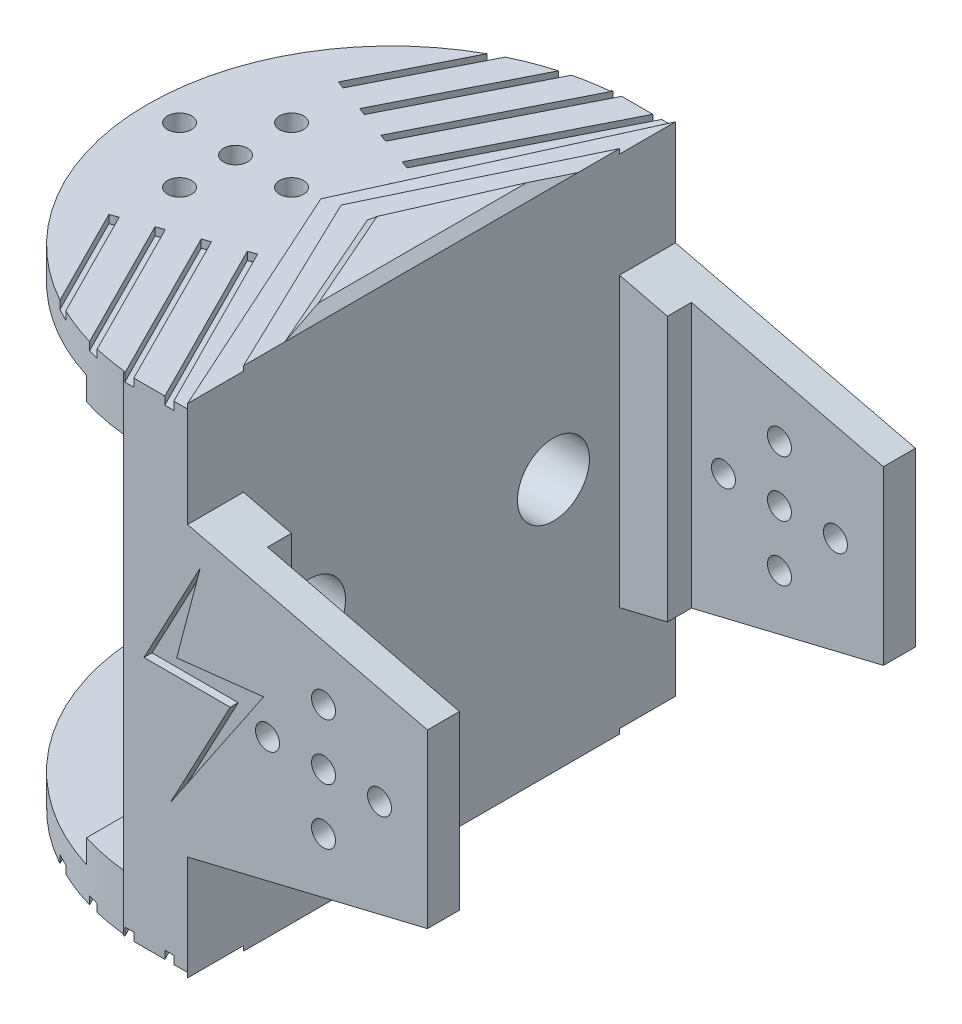
from build123d import *

# Parameters (mm, degrees)
EXTRUDE_1_DEPTH      = 61
SKETCH_2_W           = 40
SKETCH_2_H           = 53
CUT_EXTRUDE_1_DEPTH  = 61
SKETCH_3_R           = 4
CUT_EXTRUDE_2_DEPTH  = 61
SKETCH_6_W           = 61
SKETCH_6_H           = 61
EXTRUDE_3_DEPTH      = 6
EXTRUDE_4_DEPTH      = 6
CUT_EXTRUDE_4_DEPTH  = 6
SKETCH_21_R          = 4
SKETCH_21_R_2        = 1.5
EXTRUDE_10_DEPTH     = 4
SKETCH_22_R          = 1.5
CUT_EXTRUDE_11_DEPTH = 4
SKETCH_23_W          = 61
SKETCH_23_H          = 61
CUT_EXTRUDE_12_DEPTH = 2
CUT_EXTRUDE_START    = -103
SKETCH_24_W          = 18.957699184
SKETCH_24_H          = 3.1
CUT_EXTRUDE_13_DEPTH = 141
SKETCH_25_R          = 4
SKETCH_25_R_2        = 1.5
EXTRUDE_11_DEPTH     = 4
SKETCH_26_R          = 1.5
EXTRUDE_12_DEPTH     = 7
CUT_EXTRUDE_14_DEPTH = 3
SKETCH_30_R          = 4.5
CUT_EXTRUDE_15_DEPTH = 46
EXTRUDE_14_DEPTH     = 0.6
EXTRUDE_15_DEPTH     = 0.6
EXTRUDE_16_DEPTH     = 1
EXTRUDE_16_TAPER     = 48
CUT_EXTRUDE_16_DEPTH = 1
CUT_EXTRUDE_17_DEPTH = 1


with BuildPart() as part:
    # 草图1 → 凸台-拉伸1 (new body)
    with BuildSketch(Plane(origin=(0, 0, 0), x_dir=(1, 0, 0), z_dir=(0, 1, 0))):
        with BuildLine():
            Line((43.616831607, -30.5), (50.616831607, -30.5))
            Line((50.616831607, -30.5), (50.616831607, 30.5))
            Line((50.616831607, 30.5), (43.616831607, 30.5))
            ThreePointArc((43.616831607, 30.5), (13.116831607, 0), (43.616831607, -30.5))
        make_face()
    extrude(amount=EXTRUDE_1_DEPTH)

    # 草图2 → 切除-拉伸1 (cut)
    with BuildSketch(Plane.XY.offset(30.5)):
        with Locations((26.616831607, 30.5)):
            Rectangle(SKETCH_2_W, SKETCH_2_H)
    extrude(amount=-CUT_EXTRUDE_1_DEPTH, mode=Mode.SUBTRACT)

    # 草图3 → 切除-拉伸2 (cut)
    with BuildSketch(Plane(origin=(0, 61, 0), x_dir=(1, 0, 0), z_dir=(0, 1, 0))):
        with Locations((24.116831607, 0)):
            Circle(SKETCH_3_R)
    extrude(amount=-CUT_EXTRUDE_2_DEPTH, mode=Mode.SUBTRACT)

    # 草图6 → 凸台-拉伸3 (add)
    with BuildSketch(Plane.ZY.offset(-46.616831607)):
        with Locations((0, 30.5)):
            Rectangle(SKETCH_6_W, SKETCH_6_H)
    extrude(amount=EXTRUDE_3_DEPTH)

    # 草图7 → 凸台-拉伸4 (add)
    with BuildSketch(Plane.XZ.offset(-57)):
        with BuildLine():
            Line((40.616831607, 30.352100422), (40.616831607, -30.352100422))
            ThreePointArc((40.616831607, -30.352100422), (13.116831607, 0), (40.616831607, 30.352100422))
        make_face()
    extrude_4 = extrude(amount=EXTRUDE_4_DEPTH)

    # 草图8 → 切除-拉伸4 (cut)
    with BuildSketch(Plane.XZ.offset(-51)):
        Polygon((9.690406562, -10), (9.690406562, 10), (24.116831607, 30.269119374), (34.616831607, 33.638775852), (34.616831607, -30.352100422), (24.116831607, -25.227142121), align=None)
    cut_extrude_4 = extrude(amount=-CUT_EXTRUDE_4_DEPTH, mode=Mode.SUBTRACT)

    # 草图21 → 凸台-拉伸10 (add)
    with BuildSketch(Plane(origin=(0, 61, 0), x_dir=(1, 0, 0), z_dir=(0, 1, 0))):
        with Locations((24.116831607, 0)):
            Circle(SKETCH_21_R)
        with Locations((24.116831607, 0)):
            Circle(SKETCH_21_R_2, mode=Mode.SUBTRACT)
    extrude(amount=-EXTRUDE_10_DEPTH)

    # 草图22 → 切除-拉伸11 (cut)
    with BuildSketch(Plane(origin=(0, 61, 0), x_dir=(1, 0, 0), z_dir=(0, 1, 0))):
        with Locations((31.116831607, 0)):
            Circle(SKETCH_22_R)
        with Locations((24.116831607, -7)):
            Circle(SKETCH_22_R)
        with Locations((17.116831607, 0)):
            Circle(SKETCH_22_R)
        with Locations((24.116831607, 7)):
            Circle(SKETCH_22_R)
    cut_extrude_11 = extrude(amount=-CUT_EXTRUDE_11_DEPTH, mode=Mode.SUBTRACT)

    # 草图23 → 切除-拉伸12 (cut)
    with BuildSketch(Plane(origin=(50.616831607, 0, 0), x_dir=(0, 0, -1), z_dir=(1, 0, 0))):
        with Locations((0, 30.5)):
            Rectangle(SKETCH_23_W, SKETCH_23_H)
    extrude(amount=-CUT_EXTRUDE_12_DEPTH, mode=Mode.SUBTRACT)

    # 草图24 → 切除-拉伸13 (cut)
    with BuildSketch(Plane.XY.offset(30.5).offset(CUT_EXTRUDE_START)):
        with Locations((31.137982015, 52.55)):
            Rectangle(SKETCH_24_W, SKETCH_24_H)
    cut_extrude_13 = extrude(amount=CUT_EXTRUDE_13_DEPTH, mode=Mode.SUBTRACT)

    # 镜向1: 凸台-拉伸4, 切除-拉伸4, 切除-拉伸11, 切除-拉伸13 across plane
    add(extrude_4.mirror(Plane(origin=(0, 30.5, 0), x_dir=(0, 0, 1), z_dir=(0, -1, 0))))
    add(cut_extrude_4.mirror(Plane(origin=(0, 30.5, 0), x_dir=(0, 0, 1), z_dir=(0, -1, 0))), mode=Mode.SUBTRACT)
    add(cut_extrude_11.mirror(Plane(origin=(0, 30.5, 0), x_dir=(0, 0, 1), z_dir=(0, -1, 0))), mode=Mode.SUBTRACT)
    add(cut_extrude_13.mirror(Plane(origin=(0, 30.5, 0), x_dir=(0, 0, 1), z_dir=(0, -1, 0))), mode=Mode.SUBTRACT)

    # 草图25 → 凸台-拉伸11 (add)
    with BuildSketch(Plane.XZ):
        with Locations((24.116831607, 0)):
            Circle(SKETCH_25_R)
        with Locations((24.116831607, 0)):
            Circle(SKETCH_25_R_2, mode=Mode.SUBTRACT)
    extrude(amount=-EXTRUDE_11_DEPTH)

    # 草图26 → 凸台-拉伸12 (add)
    with BuildSketch(Plane.XY.offset(30.5)):
        Polygon((48.616831607, 12.5), (48.616831607, 48.5), (78.616831607, 41.256266774), (78.616831607, 19.743733226), align=None)
        with Locations((65.616831607, 30.5)):
            Circle(SKETCH_26_R, mode=Mode.SUBTRACT)
        with Locations((65.616831607, 37.5)):
            Circle(SKETCH_26_R, mode=Mode.SUBTRACT)
        with Locations((72.616831607, 30.5)):
            Circle(SKETCH_26_R, mode=Mode.SUBTRACT)
        with Locations((65.616831607, 23.5)):
            Circle(SKETCH_26_R, mode=Mode.SUBTRACT)
        with Locations((58.616831607, 30.5)):
            Circle(SKETCH_26_R, mode=Mode.SUBTRACT)
    extrude_12 = extrude(amount=-EXTRUDE_12_DEPTH)

    # 草图27 → 切除-拉伸14 (cut)
    with BuildSketch(Plane(origin=(0, 0, 23.5), x_dir=(-1, 0, 0), z_dir=(0, 0, -1))):
        Polygon((-65.616831607, 49.155948688), (-88.62878141, 40.6), (-88.62878141, 5.471682321), (-65.616831607, 5.471682321), (-55.516831607, 5.471682321), (-54.616831607, 7.907008969), (-54.616831607, 48.5), (-55.516831607, 53.096755827), align=None)
    cut_extrude_14 = extrude(amount=-CUT_EXTRUDE_14_DEPTH, mode=Mode.SUBTRACT)

    # 镜向2: 凸台-拉伸12, 切除-拉伸14 across plane
    add(extrude_12.mirror(Plane.XY))
    add(cut_extrude_14.mirror(Plane.XY), mode=Mode.SUBTRACT)

    # 草图30 → 切除-拉伸15 (cut)
    with BuildSketch(Plane(origin=(48.616831607, 0, 0), x_dir=(0, 0, -1), z_dir=(1, 0, 0))):
        with Locations((-15.25, 30.5)):
            Circle(SKETCH_30_R)
        with Locations((15.25, 30.5)):
            Circle(SKETCH_30_R)
    extrude(amount=-CUT_EXTRUDE_15_DEPTH, mode=Mode.SUBTRACT)

    # 草图31 → 凸台-拉伸14 (add)
    with BuildSketch(Plane(origin=(0, 61, 0), x_dir=(1, 0, 0), z_dir=(0, 1, 0))):
        Polygon((48.616831607, 30.5), (34.786624989, 0), (48.616831607, -30.5), align=None)
    extrude_14 = extrude(amount=EXTRUDE_14_DEPTH)

    # 草图32 → 凸台-拉伸15 (add)
    with BuildSketch(Plane(origin=(0, 61.6, 0), x_dir=(1, 0, 0), z_dir=(0, 1, 0))):
        Polygon((48.616831607, 23.5), (37.328660261, 0), (48.616831607, -23.5), align=None)
    extrude_15 = extrude(amount=EXTRUDE_15_DEPTH)

    # 草图33 → 凸台-拉伸16 (add)
    with BuildSketch(Plane(origin=(0, 62.2, 0), x_dir=(1, 0, 0), z_dir=(0, 1, 0))):
        Polygon((48.616831607, 18.308068361), (40.592556225, 0), (48.616831607, -18.308068361), align=None)
    extrude_16 = extrude(amount=EXTRUDE_16_DEPTH, taper=EXTRUDE_16_TAPER)

    # 草图34 → 切除-拉伸16 (cut)
    with BuildSketch(Plane(origin=(0, 61, 0), x_dir=(1, 0, 0), z_dir=(0, 1, 0))):
        Polygon((36.215945499, 9.330034221), (48.049296547, 32.77894458), (47.156533889, 33.229471866), (35.271831325, 9.678803595), align=None)
        Polygon((27.787246694, 12.443716957), (26.84313252, 12.792486331), (37.156533889, 33.229471866), (38.049296547, 32.77894458), align=None)
        Polygon((32.001596097, 10.886875589), (43.049296547, 32.77894458), (42.156533889, 33.229471866), (31.057481922, 11.235644963), align=None)
        Polygon((23.572897292, 14.000558325), (22.628783117, 14.349327699), (32.156533889, 33.229471866), (33.049296547, 32.77894458), align=None)
        Polygon((32.001596097, -10.886875589), (31.057481922, -11.235644963), (42.156533889, -33.229471866), (43.049296547, -32.77894458), align=None)
        Polygon((36.215945499, -9.330034221), (35.271831325, -9.678803595), (47.156533889, -33.229471866), (48.049296547, -32.77894458), align=None)
        Polygon((33.049296547, -32.77894458), (32.156533889, -33.229471866), (22.628783117, -14.349327699), (23.572897292, -14.000558325), align=None)
        Polygon((38.049296547, -32.77894458), (37.156533889, -33.229471866), (26.84313252, -12.792486331), (27.787246694, -12.443716957), align=None)
    cut_extrude_16 = extrude(amount=-CUT_EXTRUDE_16_DEPTH, mode=Mode.SUBTRACT)

    # 草图35 → 切除-拉伸17 (cut)
    with BuildSketch(Plane.XY.offset(30.5)):
        Polygon((50.215248512, 44.601766544), (43.170813126, 31.382579155), (53.95488705, 31.382579155), (46.430297324, 17.262361399), (58.129367278, 34.600407664), (47.258325017, 33.382850931), align=None)
    cut_extrude_17 = extrude(amount=-CUT_EXTRUDE_17_DEPTH, mode=Mode.SUBTRACT)

    # 镜向3: 切除-拉伸17 across plane
    add(cut_extrude_17.mirror(Plane.XY), mode=Mode.SUBTRACT)

    # 镜向4: 凸台-拉伸14, 凸台-拉伸15, 凸台-拉伸16, 切除-拉伸16 across plane
    add(extrude_14.mirror(Plane(origin=(0, 30.5, 0), x_dir=(0, 0, 1), z_dir=(0, -1, 0))))
    add(extrude_15.mirror(Plane(origin=(0, 30.5, 0), x_dir=(0, 0, 1), z_dir=(0, -1, 0))))
    add(extrude_16.mirror(Plane(origin=(0, 30.5, 0), x_dir=(0, 0, 1), z_dir=(0, -1, 0))))
    add(cut_extrude_16.mirror(Plane(origin=(0, 30.5, 0), x_dir=(0, 0, 1), z_dir=(0, -1, 0))), mode=Mode.SUBTRACT)


solid = part.part
